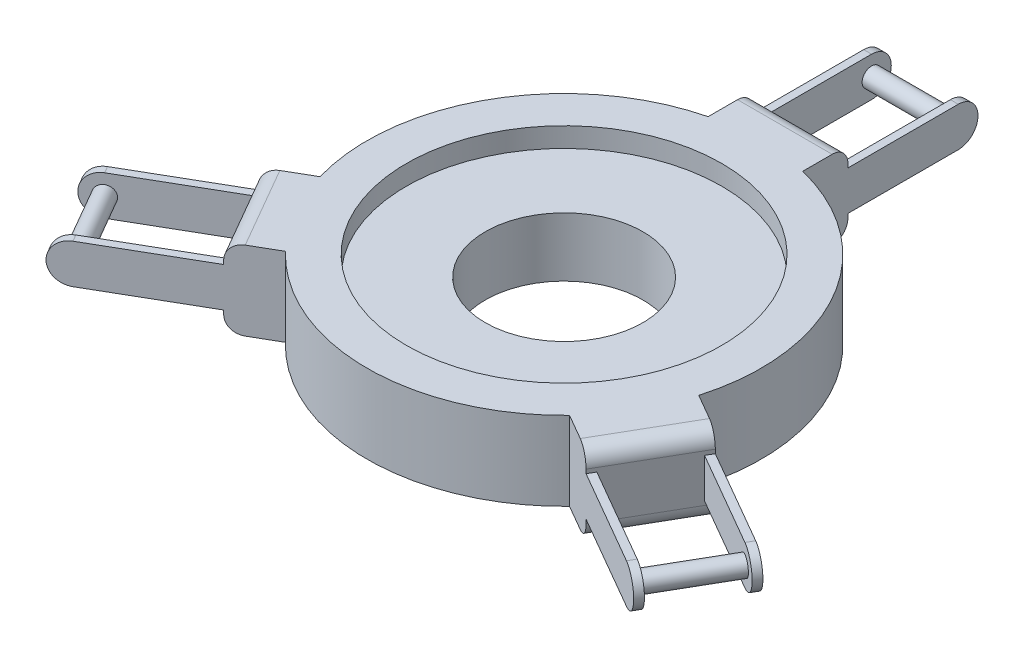
from build123d import *

# Parameters (mm, degrees)
BOSS_EXTRUDE1_DEPTH      = 50
SKETCH3_R                = 50
CUT_EXTRUDE1_DEPTH       = 50
BOSS_EXTRUDE2_START      = 25
BOSS_EXTRUDE2_DEPTH      = 5
FILLET1_R                = 10
SKETCH6_R                = 100
CUT_EXTRUDE2_DEPTH       = 12.5
BOSS_EXTRUDE3_START      = -26
SKETCH7_R                = 6
BOSS_EXTRUDE3_DEPTH      = 51
CIRPATTERN1_COUNT        = 3
CIRPATTERN1_START        = 25
CIRPATTERN1_COPY_1_DEPTH = 5
CIRPATTERN1_COPY_2_DEPTH = 5


with BuildPart() as part:
    # Sketch1 → Boss-Extrude1 (new body)
    with BuildSketch(Plane(origin=(0, 0, 0), x_dir=(1, 0, 0), z_dir=(0, 1, 0))):
        with BuildLine():
            Line((0, 150), (-30, 150))
            Line((-30, 150), (-30, 121.346610995))
            ThreePointArc((-30, 121.346610995), (-108.253175473, 62.5), (-120.089247785, -34.692543384))
            Line((-120.089247785, -34.692543384), (-144.903810568, -49.019237886))
            Line((-144.903810568, -49.019237886), (-129.903810568, -75))
            Line((-129.903810568, -75), (-114.903810568, -100.980762114))
            Line((-114.903810568, -100.980762114), (-90.089247785, -86.654067611))
            ThreePointArc((-90.089247785, -86.654067611), (0, -125), (90.089247785, -86.654067611))
            Line((90.089247785, -86.654067611), (114.903810568, -100.980762114))
            Line((114.903810568, -100.980762114), (129.903810568, -75))
            Line((129.903810568, -75), (144.903810568, -49.019237886))
            Line((144.903810568, -49.019237886), (120.089247785, -34.692543384))
            ThreePointArc((120.089247785, -34.692543384), (108.253175473, 62.5), (30, 121.346610995))
            Line((30, 121.346610995), (30, 150))
            Line((30, 150), (0, 150))
        make_face()
    extrude(amount=BOSS_EXTRUDE1_DEPTH)

    # Sketch3 → Cut-Extrude1 (cut)
    with BuildSketch(Plane(origin=(0, 50, 0), x_dir=(1, 0, 0), z_dir=(0, 1, 0))):
        Circle(SKETCH3_R)
    extrude(amount=-CUT_EXTRUDE1_DEPTH, mode=Mode.SUBTRACT)

    # Sketch4 → Boss-Extrude2 (add)
    with BuildSketch(Plane(origin=(0, 0, 0), x_dir=(0, 0, -1), z_dir=(1, 0, 0)).offset(BOSS_EXTRUDE2_START)):
        with BuildLine():
            Line((150, 37.5), (220, 37.5))
            ThreePointArc((220, 37.5), (232.5, 25), (220, 12.5))
            Line((220, 12.5), (150, 12.5))
            ThreePointArc((150, 12.5), (137.5, 25), (150, 37.5))
        make_face()
    boss_extrude2 = extrude(amount=BOSS_EXTRUDE2_DEPTH)

    # Mirror1: Boss-Extrude2 across plane
    add(boss_extrude2.mirror(Plane(origin=(0, 0, 0), x_dir=(0, 0, 1), z_dir=(1, 0, 0))))

    # Fillet1
    fillet1_edges = [part.edges().sort_by_distance(p)[0] for p in [
        (-129.903810568, 50, 75),
        (0, 0, -150),
        (129.903810568, 0, 75),
        (-129.903810568, 0, 75),
        (129.903810568, 50, 75),
        (0, 50, -150),
    ]]
    fillet(fillet1_edges, radius=FILLET1_R)

    # Sketch6 → Cut-Extrude2 (cut)
    with BuildSketch(Plane(origin=(0, 50, 0), x_dir=(1, 0, 0), z_dir=(0, 1, 0))):
        Circle(SKETCH6_R)
    extrude(amount=-CUT_EXTRUDE2_DEPTH, mode=Mode.SUBTRACT)

    # Sketch7 → Boss-Extrude3 (add)
    with BuildSketch(Plane(origin=(0, 0, 0), x_dir=(0, 0, -1), z_dir=(1, 0, 0)).offset(BOSS_EXTRUDE3_START)):
        with Locations((220, 25)):
            Circle(SKETCH7_R)
    boss_extrude3 = extrude(amount=BOSS_EXTRUDE3_DEPTH)

    # CirPattern1: Boss-Extrude3, Boss-Extrude2 ×3 about axis
    cirpattern1_axis = Axis((0, 0, 0), (0, 1, 0))
    for i in range(1, CIRPATTERN1_COUNT):
        add(boss_extrude3.rotate(cirpattern1_axis, i * 360 / CIRPATTERN1_COUNT))
        add(boss_extrude2.rotate(cirpattern1_axis, i * 360 / CIRPATTERN1_COUNT))

    # CirPattern1 copy 1 sketch → CirPattern1 copy 1 (add)
    with BuildSketch(Plane(origin=(0, 0, 0), x_dir=(-0.866025404, 0, 0.5), z_dir=(0.5, 0, 0.866025404)).offset(CIRPATTERN1_START)):
        with BuildLine():
            Line((150, -37.5), (220, -37.5))
            ThreePointArc((220, -37.5), (232.5, -25), (220, -12.5))
            Line((220, -12.5), (150, -12.5))
            ThreePointArc((150, -12.5), (137.5, -25), (150, -37.5))
        make_face()
    extrude(amount=CIRPATTERN1_COPY_1_DEPTH)

    # CirPattern1 copy 2 sketch → CirPattern1 copy 2 (add)
    with BuildSketch(Plane(origin=(0, 0, 0), x_dir=(0.866025404, 0, 0.5), z_dir=(0.5, 0, -0.866025404)).offset(CIRPATTERN1_START)):
        with BuildLine():
            Line((150, -37.5), (220, -37.5))
            ThreePointArc((220, -37.5), (232.5, -25), (220, -12.5))
            Line((220, -12.5), (150, -12.5))
            ThreePointArc((150, -12.5), (137.5, -25), (150, -37.5))
        make_face()
    extrude(amount=CIRPATTERN1_COPY_2_DEPTH)


solid = part.part
